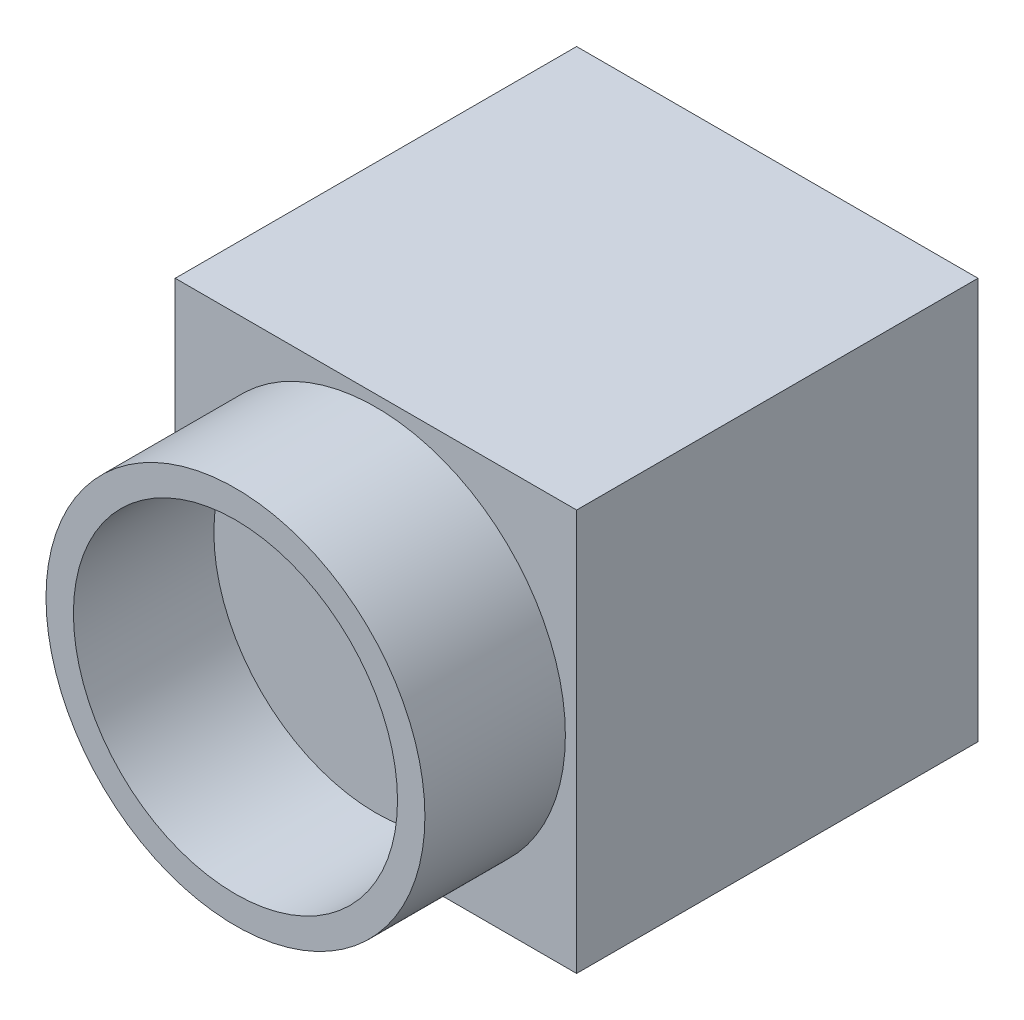
from build123d import *

# Parameters (mm, degrees)
SKETCH2_W           = 29.29
SKETCH2_H           = 29.29
BOSS_EXTRUDE1_DEPTH = 14.645
SKETCH3_R           = 13.825
BOSS_EXTRUDE2_DEPTH = 10.25
SKETCH4_R           = 11.825
CUT_EXTRUDE1_DEPTH  = 10.25


with BuildPart() as part:
    # Sketch2 → Boss-Extrude1 (new body, symmetric)
    with BuildSketch(Plane(origin=(0, 0, 0), x_dir=(1, 0, 0), z_dir=(0, 1, 0))):
        Rectangle(SKETCH2_W, SKETCH2_H)
    extrude(amount=BOSS_EXTRUDE1_DEPTH, both=True)

    # Sketch3 → Boss-Extrude2 (add)
    with BuildSketch(Plane.XY.offset(14.645)):
        Circle(SKETCH3_R)
    extrude(amount=BOSS_EXTRUDE2_DEPTH)

    # Sketch4 → Cut-Extrude1 (cut)
    with BuildSketch(Plane.XY.offset(24.895)):
        Circle(SKETCH4_R)
    extrude(amount=-CUT_EXTRUDE1_DEPTH, mode=Mode.SUBTRACT)


solid = part.part
